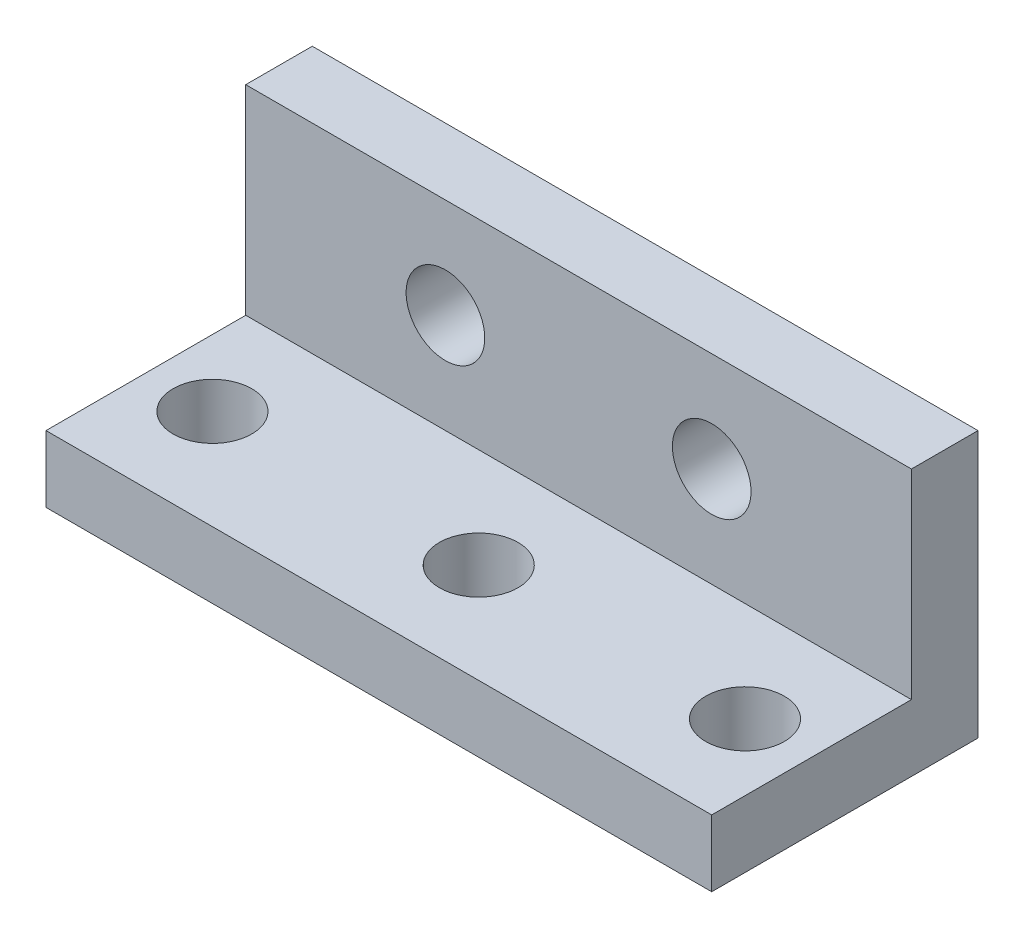
from build123d import *

# Parameters (mm, degrees)
SKETCH1_W           = 10.16
SKETCH1_H           = 10.16
BOSS_EXTRUDE1_DEPTH = 25.4
SKETCH2_W           = 7.62
SKETCH2_H           = 7.62
CUT_EXTRUDE1_DEPTH  = 26.4
SKETCH3_R           = 1.5
CUT_EXTRUDE2_DEPTH  = 3.54
SKETCH4_R           = 1.5
CUT_EXTRUDE3_DEPTH  = 3.54


with BuildPart() as part:
    # Sketch1 → Boss-Extrude1 (new body)
    with BuildSketch(Plane(origin=(0, 0, 0), x_dir=(0, 0, -1), z_dir=(1, 0, 0))):
        with Locations((5.08, 5.08)):
            Rectangle(SKETCH1_W, SKETCH1_H)
    extrude(amount=BOSS_EXTRUDE1_DEPTH)

    # Sketch2 → Cut-Extrude1 (cut, through all)
    with BuildSketch(Plane(origin=(25.4, 0, 0), x_dir=(0, 0, -1), z_dir=(1, 0, 0))):
        with Locations((3.81, 6.35)):
            Rectangle(SKETCH2_W, SKETCH2_H)
    extrude(amount=-CUT_EXTRUDE1_DEPTH, mode=Mode.SUBTRACT)

    # Sketch3 → Cut-Extrude2 (cut, through all)
    with BuildSketch(Plane.XY.offset(-7.62)):
        with Locations((7.62, 6.35)):
            Circle(SKETCH3_R)
        with Locations((17.78, 6.35)):
            Circle(SKETCH3_R)
    extrude(amount=-CUT_EXTRUDE2_DEPTH, mode=Mode.SUBTRACT)

    # Sketch4 → Cut-Extrude3 (cut, through all)
    with BuildSketch(Plane(origin=(0, 2.54, 0), x_dir=(1, 0, 0), z_dir=(0, 1, 0))):
        with Locations((2.54, 3.81)):
            Circle(SKETCH4_R)
        with Locations((22.86, 3.81)):
            Circle(SKETCH4_R)
        with Locations((12.7, 3.81)):
            Circle(SKETCH4_R)
    extrude(amount=-CUT_EXTRUDE3_DEPTH, mode=Mode.SUBTRACT)


solid = part.part
